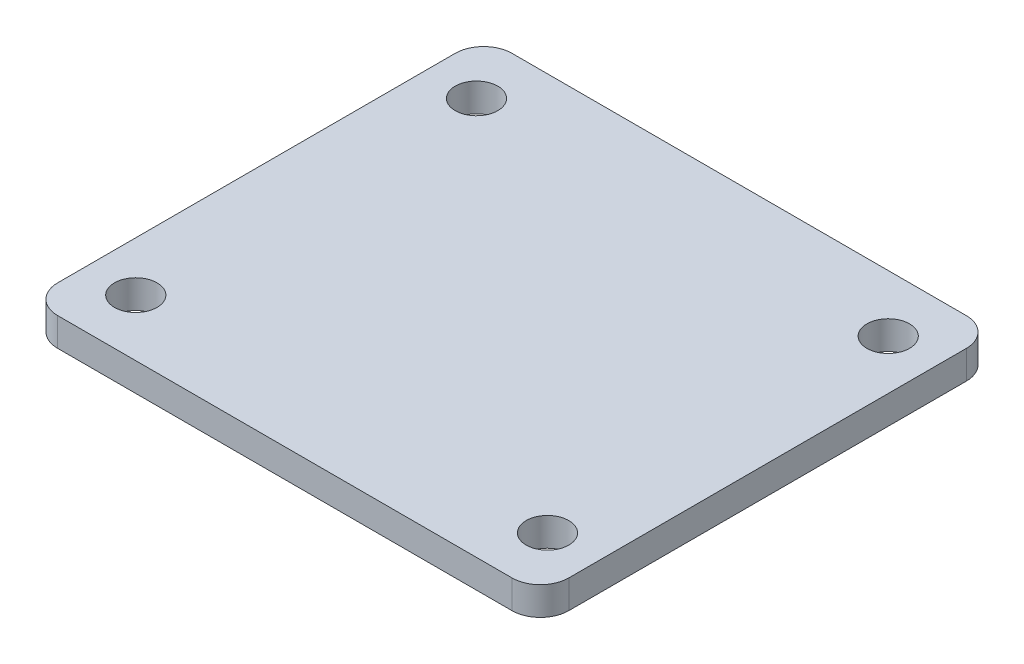
from build123d import *

# Parameters (mm, degrees)
SKETCH1_W                    = 114.3
SKETCH1_H                    = 101.6
BOSS_EXTRUDE1_DEPTH          = 6.35
FILLET1_R                    = 6.35
F_3_8_0_375_DIAMETER_HOLE1_D = 9.525


with BuildPart() as part:
    # Sketch1 → Boss-Extrude1 (new body)
    with BuildSketch(Plane(origin=(0, 0, 0), x_dir=(1, 0, 0), z_dir=(0, 1, 0))):
        Rectangle(SKETCH1_W, SKETCH1_H)
    extrude(amount=BOSS_EXTRUDE1_DEPTH)

    # Fillet1
    fillet1_edges = [part.edges().sort_by_distance(p)[0] for p in [
        (-57.15, 3.175, -50.8),
        (57.15, 3.175, -50.8),
        (57.15, 3.175, 50.8),
        (-57.15, 3.175, 50.8),
    ]]
    fillet(fillet1_edges, radius=FILLET1_R)

    # 3/8 (0.375) Diameter Hole1 (through all)
    with Locations(Plane(origin=(46.0375, 6.35, 38.1), x_dir=(0, 0, 1), z_dir=(0, 1, 0))):
        with Locations((0, 0), (0, -92.075), (-76.2, -92.075), (-76.2, 0)):
            Hole(F_3_8_0_375_DIAMETER_HOLE1_D / 2)


solid = part.part
